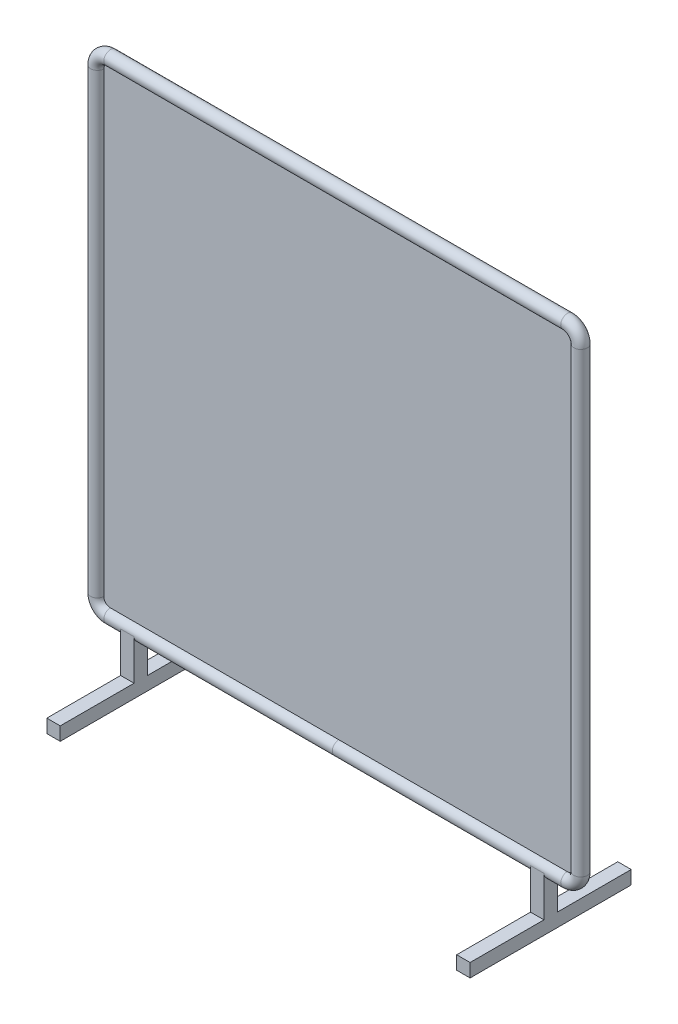
from build123d import *

# Parameters (mm, degrees)
SKETCH2_R           = 25.4
BOSS_EXTRUDE1_START = 750
BOSS_EXTRUDE1_DEPTH = 50.8
BOSS_EXTRUDE2_DEPTH = 1


with BuildPart() as part:
    # Sweep1: sweep along a path in Sketch1
    with BuildLine(Plane.XY) as sweep1_path:
        Line((-864.4, 1828.8), (864.4, 1828.8))
        ThreePointArc((864.4, 1828.8), (899.755339059, 1814.155339059), (914.4, 1778.8))
        Line((914.4, 1778.8), (914.4, 50))
        ThreePointArc((914.4, 50), (899.755339059, 14.644660941), (864.4, 0))
        Line((864.4, 0), (-864.4, 0))
        ThreePointArc((-864.4, 0), (-899.755339059, 14.644660941), (-914.4, 50))
        Line((-914.4, 50), (-914.4, 1778.8))
        ThreePointArc((-914.4, 1778.8), (-899.755339059, 1814.155339059), (-864.4, 1828.8))
    # Sketch2 → Sweep1 (sweep)
    with BuildSketch(Plane(origin=(0, 0, 0), x_dir=(0, 0, -1), z_dir=(1, 0, 0))):
        Circle(SKETCH2_R)
    sweep(path=sweep1_path.line)

    # Sketch3 → Boss-Extrude1 (add)
    with BuildSketch(Plane(origin=(0, 0, 0), x_dir=(0, 0, -1), z_dir=(1, 0, 0)).offset(BOSS_EXTRUDE1_START)):
        Polygon((-25.4, 0), (-25.4, -152.4), (-304.8, -152.4), (-304.8, -203.2), (304.8, -203.2), (304.8, -152.4), (25.4, -152.4), (25.4, 0), align=None)
    boss_extrude1 = extrude(amount=BOSS_EXTRUDE1_DEPTH)

    # Mirror1: Boss-Extrude1 across plane
    add(boss_extrude1.mirror(Plane(origin=(0, 0, 0), x_dir=(0, 0, 1), z_dir=(1, 0, 0))))


with BuildPart() as body_2:
    # Sketch1_2 → Boss-Extrude2 (new, symmetric)
    with BuildSketch(Plane.XY):
        with BuildLine():
            Line((-864.4, 1828.8), (864.4, 1828.8))
            ThreePointArc((864.4, 1828.8), (899.755339059, 1814.155339059), (914.4, 1778.8))
            Line((914.4, 1778.8), (914.4, 50))
            ThreePointArc((914.4, 50), (899.755339059, 14.644660941), (864.4, 0))
            Line((864.4, 0), (-864.4, 0))
            ThreePointArc((-864.4, 0), (-899.755339059, 14.644660941), (-914.4, 50))
            Line((-914.4, 50), (-914.4, 1778.8))
            ThreePointArc((-914.4, 1778.8), (-899.755339059, 1814.155339059), (-864.4, 1828.8))
        make_face()
    extrude(amount=BOSS_EXTRUDE2_DEPTH, both=True)


solid = Compound([part.part, body_2.part])
